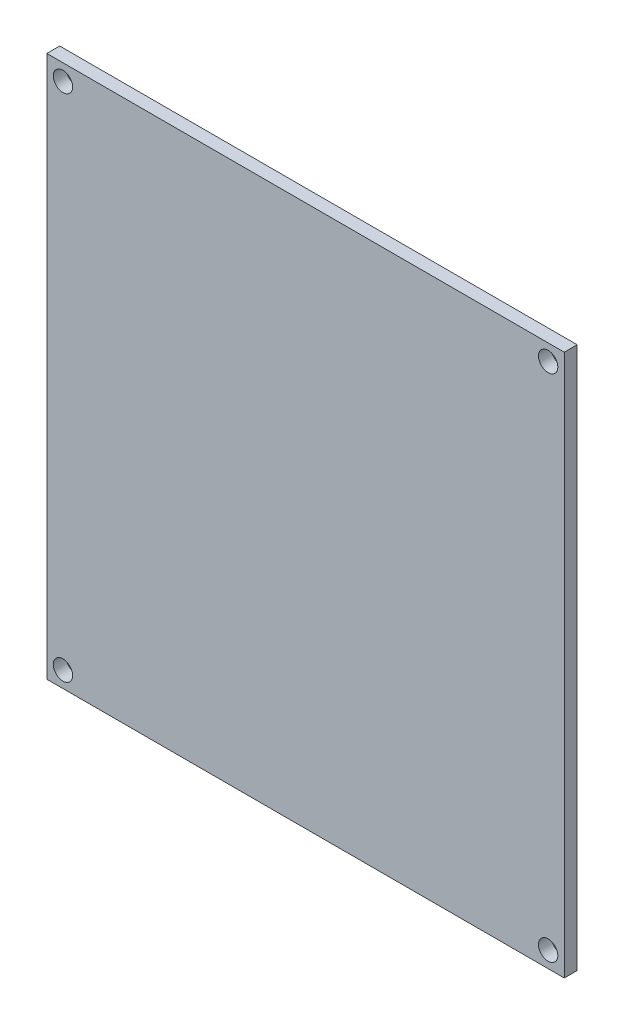
from build123d import *

# Parameters (mm, degrees)
SKETCH1_W           = 80.2
SKETCH1_H           = 84
BOSS_EXTRUDE1_DEPTH = 2
SKETCH2_R           = 1.5
CUT_EXTRUDE1_DEPTH  = 42


with BuildPart() as part:
    # Sketch1 → Boss-Extrude1 (new body)
    with BuildSketch(Plane.XY):
        with Locations((-40.1, -42)):
            Rectangle(SKETCH1_W, SKETCH1_H)
    extrude(amount=BOSS_EXTRUDE1_DEPTH)

    # Sketch2 → Cut-Extrude1 (cut)
    with BuildSketch(Plane.XY.offset(2)):
        with Locations((-77.7, -2.5)):
            Circle(SKETCH2_R)
        with Locations((-2.5, -2.5)):
            Circle(SKETCH2_R)
        with Locations((-77.7, -81.5)):
            Circle(SKETCH2_R)
        with Locations((-2.5, -81.5)):
            Circle(SKETCH2_R)
    extrude(amount=-CUT_EXTRUDE1_DEPTH, mode=Mode.SUBTRACT)


solid = part.part
